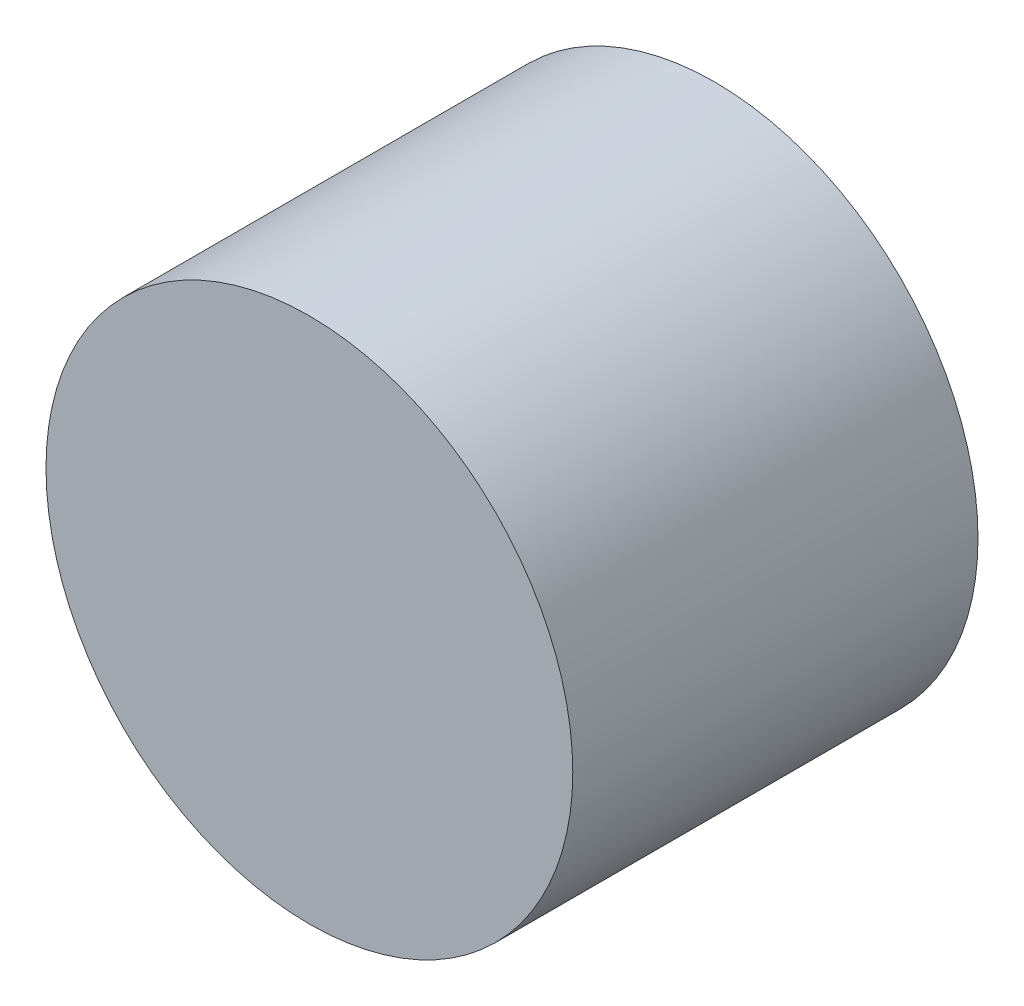
from build123d import *


with BuildPart() as part:
    # Эскиз1 → Повернуть1 (revolve)
    with BuildSketch(Plane(origin=(0, 0, 0), x_dir=(0, 0, -1), z_dir=(1, 0, 0))):
        Polygon((-6.350852961, 0), (0, 11), (0, 13), (-20, 13), (-20, 0), align=None)
    revolve(axis=Axis((0, 0, 1000), (0, 0, -1)))


solid = part.part
